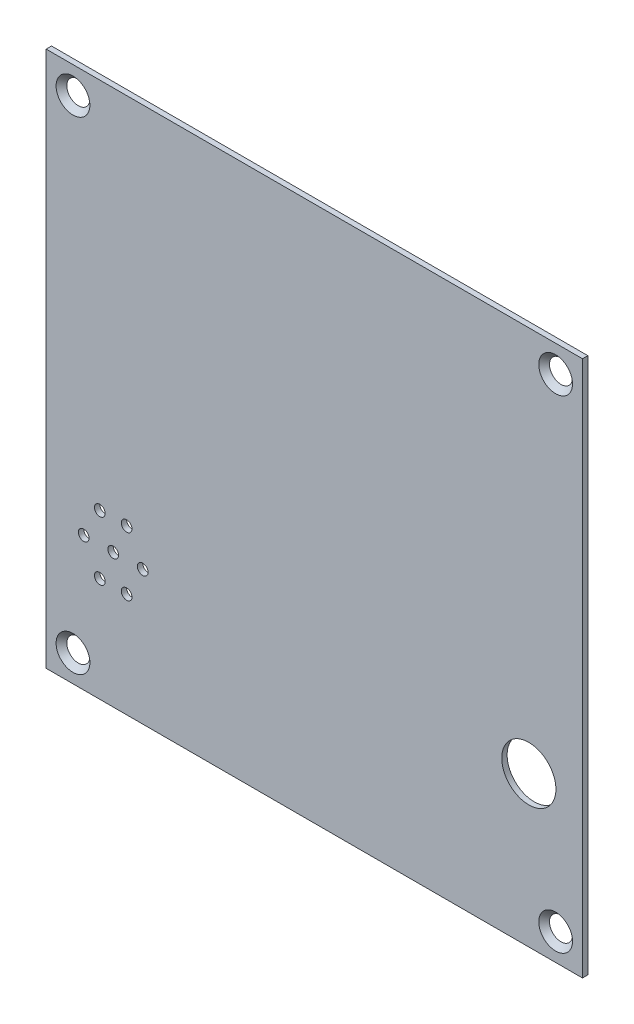
from build123d import *

# Parameters (mm, degrees)
ESQUISSE1_W                                 = 100
ESQUISSE1_H                                 = 100
BOSS_EXTRU_1_DEPTH                          = 1
FRAISAGE_POUR_VIS_T_TE_FRAIS_E_M31_AT_COUNT = 2
FRAISAGE_POUR_VIS_T_TE_FRAIS_E_M31_AT_PITCH = 90
FRAISAGE_POUR_VIS_T_TE_FRAIS_E_M31_2_COUNT  = 2
FRAISAGE_POUR_VIS_T_TE_FRAIS_E_M31_2_PITCH  = 127.279220614
FRAISAGE_POUR_VIS_T_TE_FRAIS_E_M31_3_COUNT  = 2
FRAISAGE_POUR_VIS_T_TE_FRAIS_E_M31_3_PITCH  = 90
ESQUISSE4_R                                 = 5.05
ESQUISSE4_R_2                               = 1
ENL_V_MAT_EXTRU_1_DEPTH                     = 2


with BuildPart() as part:
    # Esquisse1 → Boss.-Extru.1 (new body)
    with BuildSketch(Plane.XY):
        with Locations((50, 50)):
            Rectangle(ESQUISSE1_W, ESQUISSE1_H)
    extrude(amount=BOSS_EXTRU_1_DEPTH)

    # Esquisse3 → Fraisage pour vis à tête fraisée M31 (revolve, cut)
    with BuildSketch(Plane(origin=(5, 95, 1), x_dir=(0, -1, 0), z_dir=(1, 0, 0))):
        Polygon((0, 0), (0, 1), (1.8, 1), (1.8, 1.35), (3.15, 0), align=None)
    fraisage_pour_vis_t_te_frais_e_m31 = revolve(axis=Axis((5, 95, 7.35), (0, 0, -1)), mode=Mode.SUBTRACT)

    # Fraisage pour vis à tête fraisée M31 at: Fraisage pour vis à tête fraisée M31 ×2
    with Locations(*[(i * FRAISAGE_POUR_VIS_T_TE_FRAIS_E_M31_AT_PITCH, 0, 0) for i in range(1, FRAISAGE_POUR_VIS_T_TE_FRAIS_E_M31_AT_COUNT)]):
        add(fraisage_pour_vis_t_te_frais_e_m31, mode=Mode.SUBTRACT)

    # Fraisage pour vis _ t_te frais_e M31 2: Fraisage pour vis à tête fraisée M31 ×2
    with Locations(*[Vector(0.707106781, -0.707106781, 0) * (i * FRAISAGE_POUR_VIS_T_TE_FRAIS_E_M31_2_PITCH) for i in range(1, FRAISAGE_POUR_VIS_T_TE_FRAIS_E_M31_2_COUNT)]):
        add(fraisage_pour_vis_t_te_frais_e_m31, mode=Mode.SUBTRACT)

    # Fraisage pour vis _ t_te frais_e M31 3: Fraisage pour vis à tête fraisée M31 ×2
    with Locations(*[(0, -i * FRAISAGE_POUR_VIS_T_TE_FRAIS_E_M31_3_PITCH, 0) for i in range(1, FRAISAGE_POUR_VIS_T_TE_FRAIS_E_M31_3_COUNT)]):
        add(fraisage_pour_vis_t_te_frais_e_m31, mode=Mode.SUBTRACT)

    # Esquisse4 → Enlèv. mat.-Extru.1 (cut, through all)
    with BuildSketch(Plane.XY.offset(1)):
        with Locations((90, 28)):
            Circle(ESQUISSE4_R)
        with Locations((12.5, 25)):
            Circle(ESQUISSE4_R_2)
        with Locations((10, 19.5)):
            Circle(ESQUISSE4_R_2)
        with Locations((7, 25)):
            Circle(ESQUISSE4_R_2)
        with Locations((18, 25)):
            Circle(ESQUISSE4_R_2)
        with Locations((10, 30.5)):
            Circle(ESQUISSE4_R_2)
        with Locations((15, 30.5)):
            Circle(ESQUISSE4_R_2)
        with Locations((15, 19.5)):
            Circle(ESQUISSE4_R_2)
    extrude(amount=-ENL_V_MAT_EXTRU_1_DEPTH, mode=Mode.SUBTRACT)


solid = part.part
